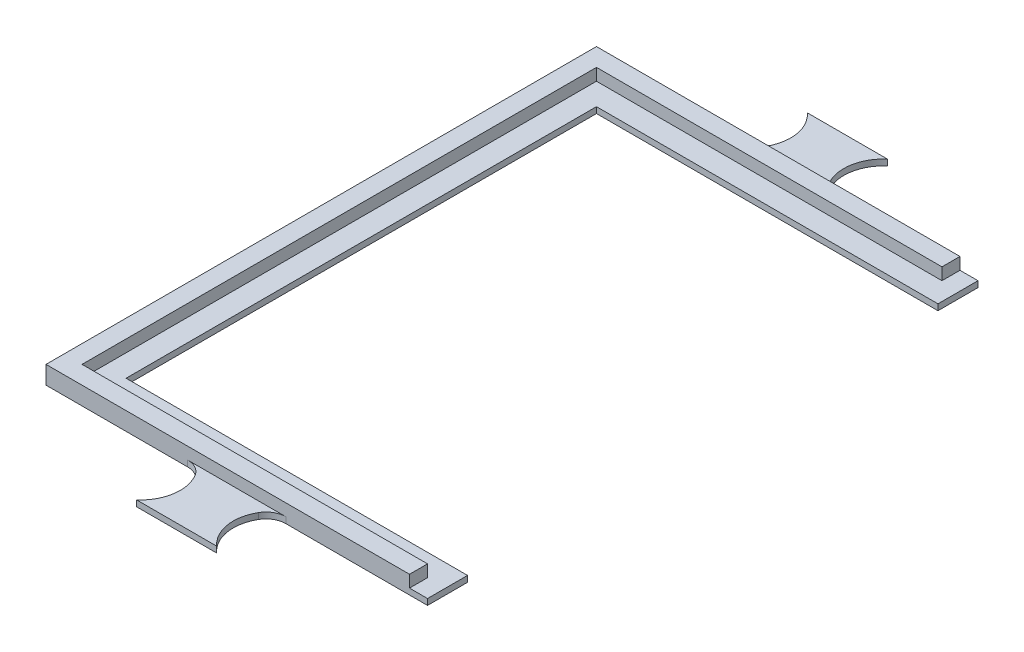
from build123d import *

# Parameters (mm, degrees)
SKETCH1_W           = 10
SKETCH1_H           = 117.5
BOSS_EXTRUDE1_DEPTH = 1.5
BOSS_EXTRUDE2_DEPTH = 3


with BuildPart() as part:
    # Sketch1 → Boss-Extrude1 (new body)
    with BuildSketch(Plane(origin=(0, 0, 0), x_dir=(1, 0, 0), z_dir=(0, 1, 0))):
        with BuildLine():
            ThreePointArc((-7.95412424, -71.25), (-9.784251259, -69.419872981), (-12.284251259, -68.75))
            Line((-12.284251259, -68.75), (-47.65, -68.75))
            Line((-47.65, -68.75), (-47.65, -58.75))
            Line((-47.65, -58.75), (47.65, -58.75))
            Line((47.65, -58.75), (47.65, -68.75))
            Line((47.65, -68.75), (12.284251259, -68.75))
            ThreePointArc((12.284251259, -68.75), (9.784251259, -69.419872981), (7.95412424, -71.25))
            ThreePointArc((7.95412424, -71.25), (6.745685452, -77.865209555), (10, -83.75))
            Line((10, -83.75), (-10, -83.75))
            ThreePointArc((-10, -83.75), (-6.745685452, -77.865209555), (-7.95412424, -71.25))
        make_face()
        with Locations((-42.65, 0)):
            Rectangle(SKETCH1_W, SKETCH1_H)
        with BuildLine():
            ThreePointArc((-7.95412424, 71.25), (-6.745685452, 77.865209555), (-10, 83.75))
            Line((-10, 83.75), (10, 83.75))
            ThreePointArc((10, 83.75), (6.745685452, 77.865209555), (7.95412424, 71.25))
            ThreePointArc((7.95412424, 71.25), (9.784251259, 69.419872981), (12.284251259, 68.75))
            Line((12.284251259, 68.75), (47.65, 68.75))
            Line((47.65, 68.75), (47.65, 58.75))
            Line((47.65, 58.75), (-47.65, 58.75))
            Line((-47.65, 58.75), (-47.65, 68.75))
            Line((-47.65, 68.75), (-12.284251259, 68.75))
            ThreePointArc((-12.284251259, 68.75), (-9.784251259, 69.419872981), (-7.95412424, 71.25))
        make_face()
    extrude(amount=BOSS_EXTRUDE1_DEPTH)

    # Sketch2 → Boss-Extrude2 (add)
    with BuildSketch(Plane(origin=(0, 1.5, 0), x_dir=(1, 0, 0), z_dir=(0, 1, 0))):
        Polygon((-43.15, 64.25), (43.15, 64.25), (43.15, 68.75), (12.284251259, 68.75), (-12.284251259, 68.75), (-47.65, 68.75), (-47.65, -68.75), (-12.284251259, -68.75), (12.284251259, -68.75), (43.15, -68.75), (43.15, -64.25), (-43.15, -64.25), align=None)
    extrude(amount=BOSS_EXTRUDE2_DEPTH)


solid = part.part
